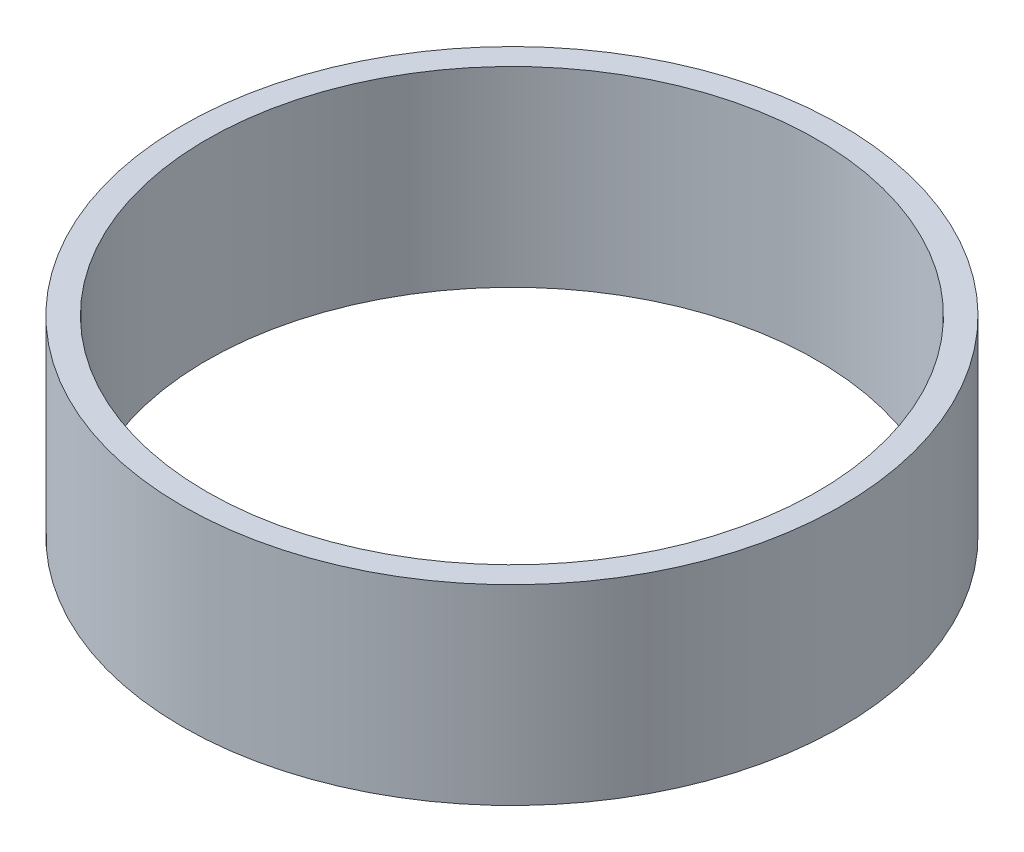
from build123d import *

# Parameters (mm, degrees)
SKETCH1_R           = 40.5
SKETCH1_R_2         = 37.5
BOSS_EXTRUDE1_DEPTH = 23.5


with BuildPart() as part:
    # Sketch1 → Boss-Extrude1 (new body)
    with BuildSketch(Plane(origin=(0, 0, 0), x_dir=(1, 0, 0), z_dir=(0, 1, 0))):
        Circle(SKETCH1_R)
        Circle(SKETCH1_R_2, mode=Mode.SUBTRACT)
    extrude(amount=BOSS_EXTRUDE1_DEPTH)


solid = part.part
